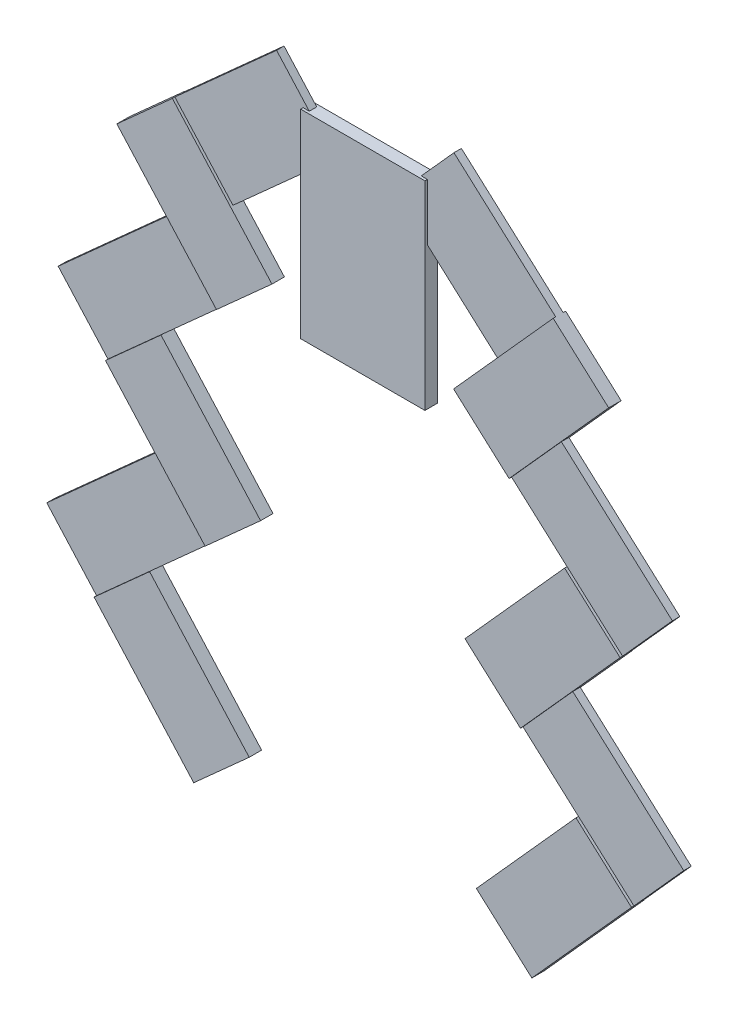
from build123d import *

# Parameters (mm, degrees)
SKETCH1_W                  = 127
SKETCH1_H                  = 203.2
BOSS_EXTRUDE1_DEPTH        = 12.7
BOSS_EXTRUDE2_DEPTH        = 3.81
BOSS_EXTRUDE2_DEPTH_BACK   = 3.81
BOSS_EXTRUDE2_2_DEPTH      = 3.81
BOSS_EXTRUDE2_2_DEPTH_BACK = 3.81
BOSS_EXTRUDE3_START        = -10.16
BOSS_EXTRUDE3_DEPTH        = 12.7
BOSS_EXTRUDE4_DEPTH        = 3.81
BOSS_EXTRUDE4_DEPTH_BACK   = 3.81
BOSS_EXTRUDE5_START        = -10.16
BOSS_EXTRUDE5_DEPTH        = 12.7
BOSS_EXTRUDE6_DEPTH        = 3.81
BOSS_EXTRUDE6_DEPTH_BACK   = 3.81
BOSS_EXTRUDE7_START        = -10.16
BOSS_EXTRUDE7_DEPTH        = 12.7


with BuildPart() as part:
    # Sketch1 → Boss-Extrude1 (new body)
    with BuildSketch(Plane.XY):
        with Locations((-63.5, 101.6)):
            Rectangle(SKETCH1_W, SKETCH1_H)
    extrude(amount=BOSS_EXTRUDE1_DEPTH)


with BuildPart() as body_2:
    # Sketch2 → Boss-Extrude2 (new body, two sides)
    with BuildSketch(Plane.XY.offset(6.35)) as boss_extrude2_sk:
        Polygon((-94.746798064, 174.248710321), (-198.717445096, 80.941719394), (-258.09462114, 147.104858415), (-154.123974108, 240.411849341), align=None)
    extrude(amount=BOSS_EXTRUDE2_DEPTH)
    extrude(boss_extrude2_sk.sketch, amount=-BOSS_EXTRUDE2_DEPTH_BACK)



with BuildPart() as body_3:
    # Sketch2 → Boss-Extrude2 2 (new body, two sides)
    with BuildSketch(Plane.XY.offset(6.35)) as boss_extrude2_2_sk:
        Polygon((-32.253201936, 174.248710321), (71.717445096, 80.941719394), (131.09462114, 147.104858415), (27.123974108, 240.411849341), align=None)
    extrude(amount=BOSS_EXTRUDE2_2_DEPTH)
    extrude(boss_extrude2_2_sk.sketch, amount=-BOSS_EXTRUDE2_2_DEPTH_BACK)


with BuildPart() as body_2_1:
    add(body_2.part)

    add(body_3.part)  # Boss-Extrude3 merges body 3
    # Sketch3 → Boss-Extrude3 (add)
    with BuildSketch(Plane.XY.offset(10.16).offset(BOSS_EXTRUDE3_START)):
        Polygon((-258.09462114, 147.104858415), (-156.305176493, 33.68233438), (-213.01643851, -17.212387944), (-314.805883157, 96.210136091), align=None)
        Polygon((29.305176493, 33.68233438), (86.01643851, -17.212387944), (187.805883157, 96.210136091), (131.09462114, 147.104858415), align=None)
    extrude(amount=BOSS_EXTRUDE3_DEPTH)

    # Sketch4 → Boss-Extrude4 (add, two sides)
    with BuildSketch(Plane.XY.offset(6.35)) as boss_extrude4_sk:
        Polygon((-213.01643851, -17.212387944), (-263.911160834, 39.498874074), (-377.333684869, -62.290570573), (-326.438962545, -119.00183259), align=None)
        Polygon((199.438962545, -119.00183259), (250.333684869, -62.290570573), (136.911160834, 39.498874074), (86.01643851, -17.212387944), align=None)
    extrude(amount=BOSS_EXTRUDE4_DEPTH)
    extrude(boss_extrude4_sk.sketch, amount=-BOSS_EXTRUDE4_DEPTH_BACK)

    # Sketch5 → Boss-Extrude5 (add)
    with BuildSketch(Plane.XY.offset(10.16).offset(BOSS_EXTRUDE5_START)):
        Polygon((-326.438962545, -119.00183259), (-269.727700528, -68.107110267), (-167.938255881, -181.529634302), (-224.649517899, -232.424356626), align=None)
        Polygon((97.649517899, -232.424356626), (40.938255881, -181.529634302), (142.727700528, -68.107110267), (199.438962545, -119.00183259), align=None)
    extrude(amount=BOSS_EXTRUDE5_DEPTH)

    # Sketch6 → Boss-Extrude6 (add, two sides)
    with BuildSketch(Plane.XY.offset(6.35)) as boss_extrude6_sk:
        Polygon((-224.649517899, -232.424356626), (-275.544240222, -175.713094608), (-388.966764257, -277.502539255), (-338.072041934, -334.213801272), align=None)
        Polygon((211.072041934, -334.213801272), (261.966764257, -277.502539255), (148.544240222, -175.713094608), (97.649517899, -232.424356626), align=None)
    extrude(amount=BOSS_EXTRUDE6_DEPTH)
    extrude(boss_extrude6_sk.sketch, amount=-BOSS_EXTRUDE6_DEPTH_BACK)

    # Sketch7 → Boss-Extrude7 (add)
    with BuildSketch(Plane.XY.offset(10.16).offset(BOSS_EXTRUDE7_START)):
        Polygon((-338.072041934, -334.213801272), (-281.360779916, -283.319078949), (-179.571335269, -396.741602984), (-236.282597287, -447.636325307), align=None)
        Polygon((211.072041934, -334.213801272), (154.360779916, -283.319078949), (52.571335269, -396.741602984), (109.282597287, -447.636325307), align=None)
    extrude(amount=BOSS_EXTRUDE7_DEPTH)


solid = Compound([part.part, body_2_1.part])
